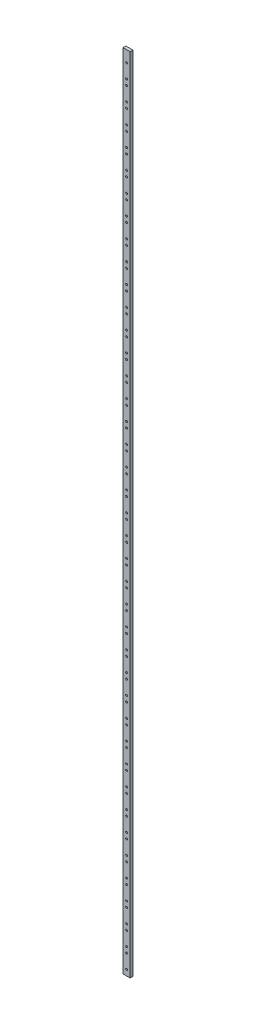
from build123d import *

# Parameters (mm, degrees)
SKETCH1_W                  = 15.875
SKETCH1_H                  = 6.35
BOSS_EXTRUDE1_DEPTH        = 1803.4
TAP_DRILL_FOR_10_32_TAP1_D = 4.0386


with BuildPart() as part:
    # Sketch1 → Boss-Extrude1 (new body)
    with BuildSketch(Plane(origin=(0, 0, 0), x_dir=(1, 0, 0), z_dir=(0, 1, 0))):
        with Locations((7.9375, 3.175)):
            Rectangle(SKETCH1_W, SKETCH1_H)
    extrude(amount=BOSS_EXTRUDE1_DEPTH)

    # Tap Drill for #10-32 Tap1 (through all)
    with Locations(Plane.XY):
        with Locations((7.9375, 12.7), (7.9375, 44.45), (7.9375, 57.15), (7.9375, 88.9), (7.9375, 101.6), (7.9375, 133.35), (7.9375, 146.05), (7.9375, 177.8), (7.9375, 190.5), (7.9375, 222.25), (7.9375, 234.95), (7.9375, 266.7), (7.9375, 279.4), (7.9375, 311.15), (7.9375, 323.85), (7.9375, 355.6), (7.9375, 368.3), (7.9375, 400.05), (7.9375, 412.75), (7.9375, 444.5), (7.9375, 457.2), (7.9375, 488.95), (7.9375, 501.65), (7.9375, 533.4), (7.9375, 546.1), (7.9375, 577.85), (7.9375, 590.55), (7.9375, 622.3), (7.9375, 635), (7.9375, 666.75), (7.9375, 679.45), (7.9375, 711.2), (7.9375, 723.9), (7.9375, 755.65), (7.9375, 768.35), (7.9375, 800.1), (7.9375, 812.8), (7.9375, 844.55), (7.9375, 857.25), (7.9375, 889), (7.9375, 901.7), (7.9375, 933.45), (7.9375, 946.15), (7.9375, 977.9), (7.9375, 990.6), (7.9375, 1022.35), (7.9375, 1035.05), (7.9375, 1066.8), (7.9375, 1079.5), (7.9375, 1111.25), (7.9375, 1123.95), (7.9375, 1155.7), (7.9375, 1168.4), (7.9375, 1200.15), (7.9375, 1212.85), (7.9375, 1244.6), (7.9375, 1257.3), (7.9375, 1289.05), (7.9375, 1301.75), (7.9375, 1333.5), (7.9375, 1346.2), (7.9375, 1377.95), (7.9375, 1390.65), (7.9375, 1422.4), (7.9375, 1435.1), (7.9375, 1466.85), (7.9375, 1479.55), (7.9375, 1511.3), (7.9375, 1524), (7.9375, 1555.75), (7.9375, 1568.45), (7.9375, 1600.2), (7.9375, 1612.9), (7.9375, 1644.65), (7.9375, 1657.35), (7.9375, 1689.1), (7.9375, 1701.8), (7.9375, 1733.55), (7.9375, 1746.25), (7.9375, 1778)):
            Hole(TAP_DRILL_FOR_10_32_TAP1_D / 2)


solid = part.part
